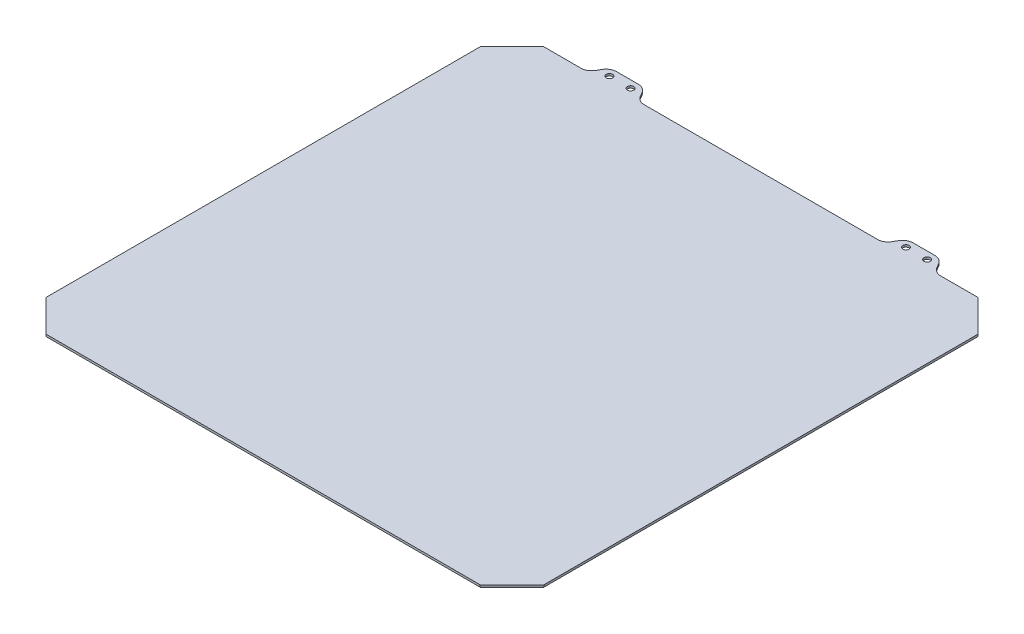
from build123d import *

# Parameters (mm, degrees)
SKETCH1_W           = 235
SKETCH1_H           = 235
BOSS_EXTRUDE1_DEPTH = 1
SKETCH2_R           = 1.5
BOSS_EXTRUDE2_DEPTH = 1
FILLET1_R           = 5
CHAMFER1_SIZE       = 15


with BuildPart() as part:
    # Sketch1 → Boss-Extrude1 (new body)
    with BuildSketch(Plane(origin=(0, 0, 0), x_dir=(1, 0, 0), z_dir=(0, 1, 0))):
        Rectangle(SKETCH1_W, SKETCH1_H)
    extrude(amount=BOSS_EXTRUDE1_DEPTH)

    # Sketch2 → Boss-Extrude2 (add)
    with BuildSketch(Plane(origin=(0, 0, 0), x_dir=(1, 0, 0), z_dir=(0, 1, 0))):
        Polygon((-82.041451884, 117.5), (-78, 124.5), (-62, 124.5), (-57.958548116, 117.5), align=None)
        with Locations((-75, 121)):
            Circle(SKETCH2_R, mode=Mode.SUBTRACT)
        with Locations((-65, 121)):
            Circle(SKETCH2_R, mode=Mode.SUBTRACT)
        Polygon((57.958548116, 117.5), (82.041451884, 117.5), (78, 124.5), (62, 124.5), align=None)
        with Locations((65, 121)):
            Circle(SKETCH2_R, mode=Mode.SUBTRACT)
        with Locations((75, 121)):
            Circle(SKETCH2_R, mode=Mode.SUBTRACT)
    extrude(amount=BOSS_EXTRUDE2_DEPTH)

    # Fillet1
    fillet1_edges = [part.edges().sort_by_distance(p)[0] for p in [
        (-82.041451884, 0.5, -117.5),
        (-57.958548116, 0.5, -117.5),
        (-62, 0.5, -124.5),
        (-78, 0.5, -124.5),
        (62, 0.5, -124.5),
        (57.958548116, 0.5, -117.5),
        (82.041451884, 0.5, -117.5),
        (78, 0.5, -124.5),
    ]]
    fillet(fillet1_edges, radius=FILLET1_R)

    # Chamfer1
    chamfer1_edges = [part.edges().sort_by_distance(p)[0] for p in [
        (-117.5, 0.5, -117.5),
        (117.5, 0.5, -117.5),
        (117.5, 0.5, 117.5),
        (-117.5, 0.5, 117.5),
    ]]
    chamfer(chamfer1_edges, length=CHAMFER1_SIZE)


solid = part.part
